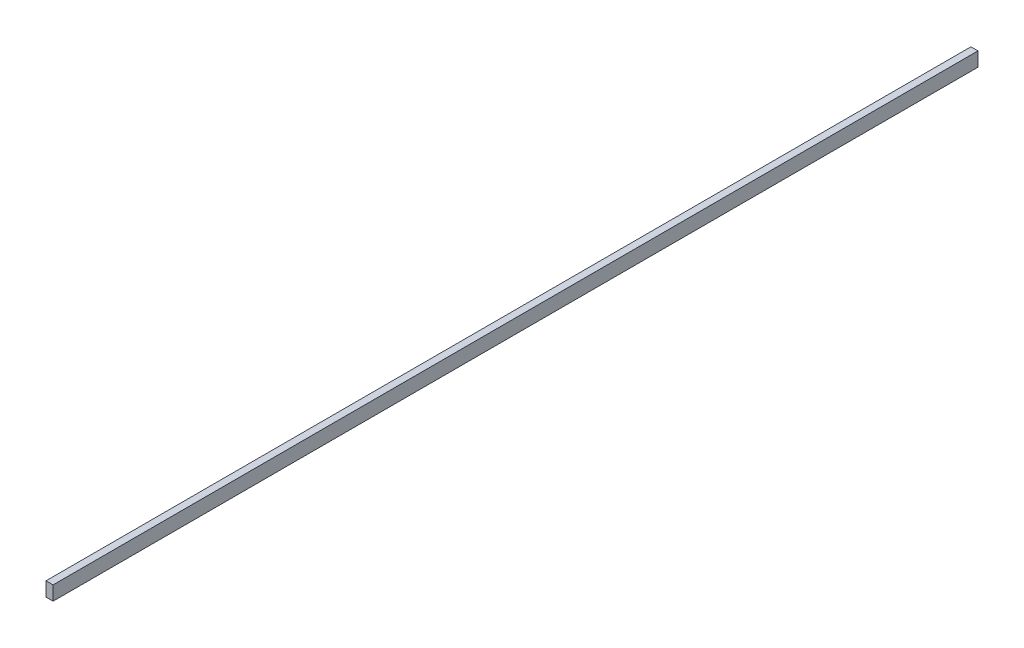
from build123d import *

# Parameters (mm, degrees)
SKETCH1_W           = 3.175
SKETCH1_H           = 6.35
BOSS_EXTRUDE1_DEPTH = 415


with BuildPart() as part:
    # Sketch1 → Boss-Extrude1 (new body)
    with BuildSketch(Plane.XY):
        with Locations((1.5875, 3.175)):
            Rectangle(SKETCH1_W, SKETCH1_H)
    extrude(amount=BOSS_EXTRUDE1_DEPTH)


solid = part.part
